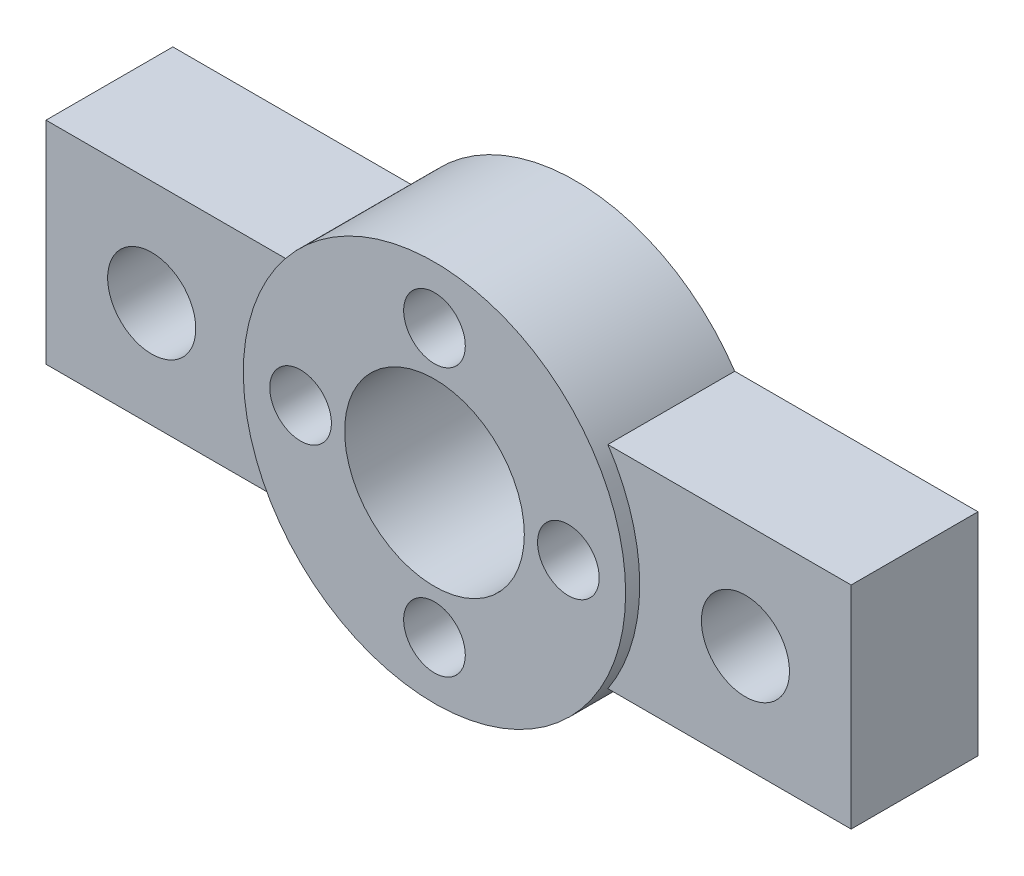
from build123d import *

# Parameters (mm, degrees)
SKETCH1_R           = 10.85
SKETCH1_R_2         = 5.1
SKETCH1_R_3         = 1.75
BOSS_EXTRUDE1_DEPTH = 8
SKETCH2_R           = 3.55
BOSS_EXTRUDE3_DEPTH = 3.2
SKETCH3_R           = 2.5
BOSS_EXTRUDE4_DEPTH = 4


with BuildPart() as part:
    # Sketch1 → Boss-Extrude1 (new body)
    with BuildSketch(Plane.XY):
        Circle(SKETCH1_R)
        Circle(SKETCH1_R_2, mode=Mode.SUBTRACT)
        with Locations((-7.6, 0)):
            Circle(SKETCH1_R_3, mode=Mode.SUBTRACT)
        with Locations((0, 7.6)):
            Circle(SKETCH1_R_3, mode=Mode.SUBTRACT)
        with Locations((7.6, 0)):
            Circle(SKETCH1_R_3, mode=Mode.SUBTRACT)
        with Locations((0, -7.6)):
            Circle(SKETCH1_R_3, mode=Mode.SUBTRACT)
    extrude(amount=BOSS_EXTRUDE1_DEPTH)

    # Sketch2 → Boss-Extrude3 (add)
    with BuildSketch(Plane(origin=(0, 0, 0), x_dir=(-1, 0, 0), z_dir=(0, 0, -1))):
        with BuildLine():
            Line((-22.85, -6), (-22.85, 6))
            Line((-22.85, 6), (-9.040049779, 6))
            ThreePointArc((-9.040049779, 6), (-10.85, 0), (-9.040049779, -6))
            Line((-9.040049779, -6), (-22.85, -6))
        make_face()
        with Locations((-16.85, 0)):
            Circle(SKETCH2_R, mode=Mode.SUBTRACT)
        with BuildLine():
            Line((22.85, -6), (22.85, 6))
            Line((22.85, 6), (9.040049779, 6))
            ThreePointArc((9.040049779, 6), (10.85, 0), (9.040049779, -6))
            Line((9.040049779, -6), (22.85, -6))
        make_face()
        with Locations((16.85, 0)):
            Circle(SKETCH2_R, mode=Mode.SUBTRACT)
    extrude(amount=-BOSS_EXTRUDE3_DEPTH)

    # Sketch3 → Boss-Extrude4 (add)
    with BuildSketch(Plane.XY.offset(3.2)):
        with BuildLine():
            Line((-9.040049779, 6), (-22.85, 6))
            Line((-22.85, 6), (-22.85, -6))
            Line((-22.85, -6), (-9.040049779, -6))
            ThreePointArc((-9.040049779, -6), (-10.85, 0), (-9.040049779, 6))
        make_face()
        with Locations((-16.85, 0)):
            Circle(SKETCH3_R, mode=Mode.SUBTRACT)
        with BuildLine():
            Line((9.040049779, -6), (22.85, -6))
            Line((22.85, -6), (22.85, 6))
            Line((22.85, 6), (9.040049779, 6))
            ThreePointArc((9.040049779, 6), (10.85, 0), (9.040049779, -6))
        make_face()
        with Locations((16.85, 0)):
            Circle(SKETCH3_R, mode=Mode.SUBTRACT)
    extrude(amount=BOSS_EXTRUDE4_DEPTH)


solid = part.part
